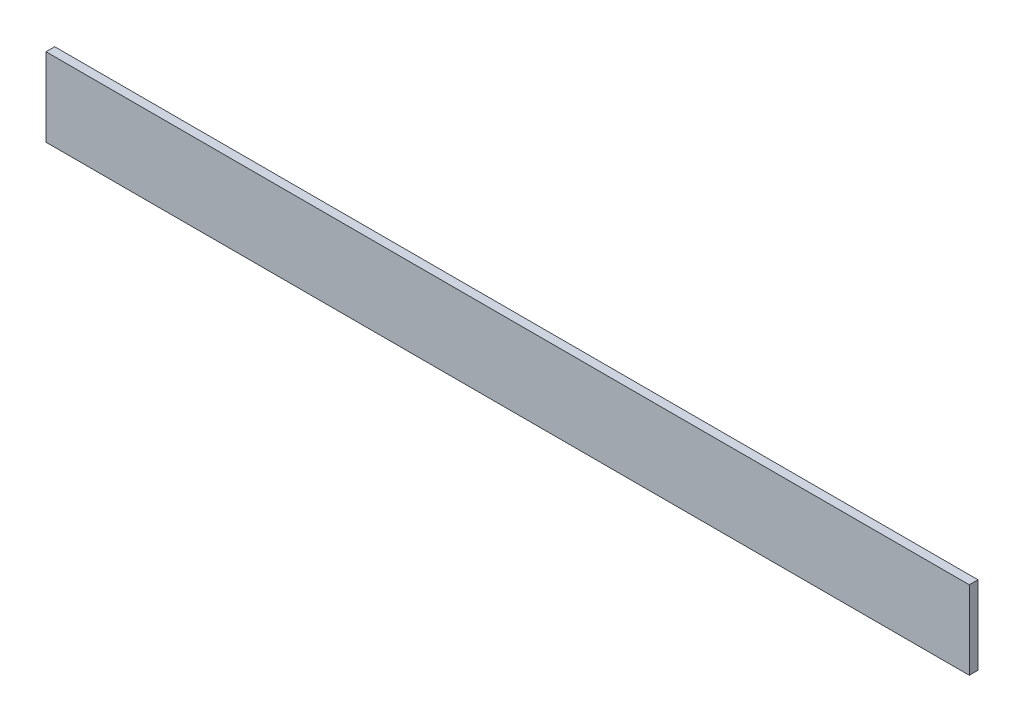
from build123d import *

# Parameters (mm, degrees)
SKETCH1_W           = 2120
SKETCH1_H           = 180
BOSS_EXTRUDE1_DEPTH = 10


with BuildPart() as part:
    # Sketch1 → Boss-Extrude1 (new body, symmetric)
    with BuildSketch(Plane.XY):
        Rectangle(SKETCH1_W, SKETCH1_H)
    extrude(amount=BOSS_EXTRUDE1_DEPTH, both=True)


solid = part.part
